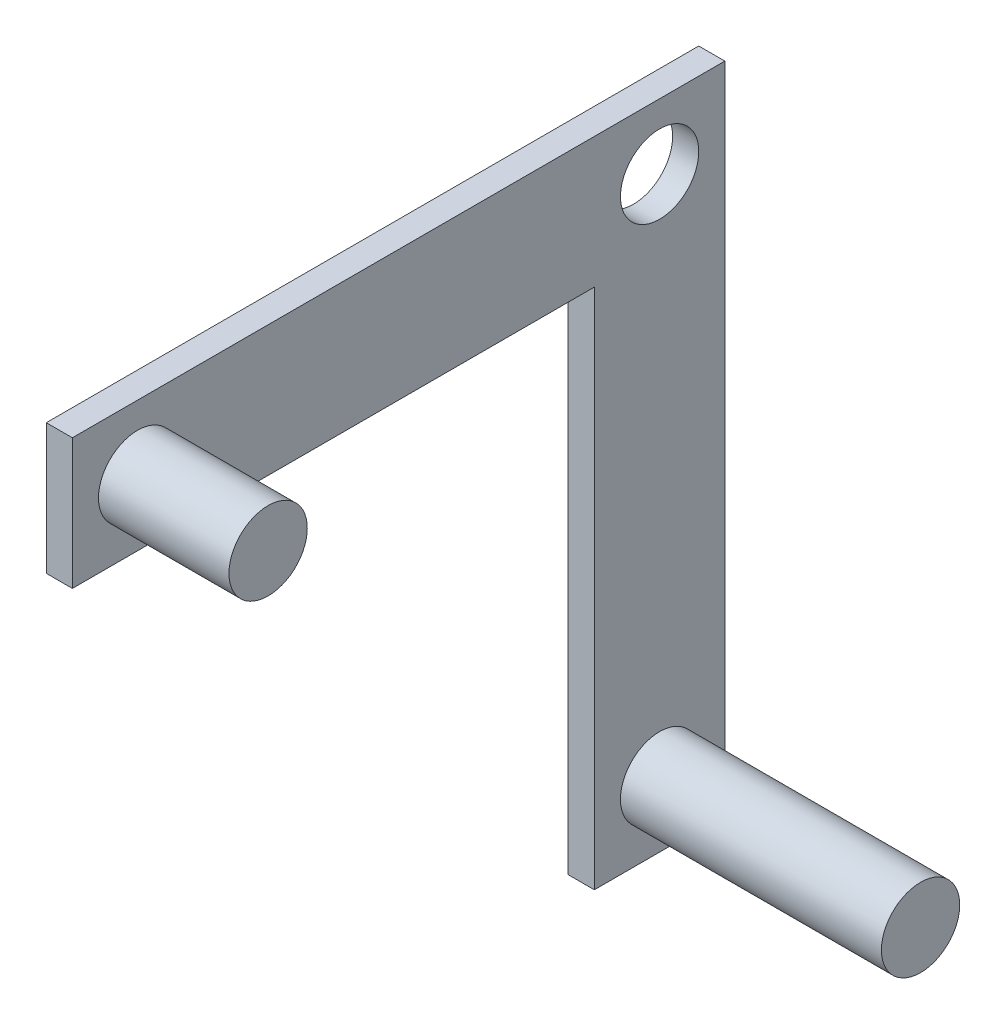
from build123d import *

# Parameters (mm, degrees)
SKETCH1_W           = 10
SKETCH1_H           = 50
BOSS_EXTRUDE1_DEPTH = 2
SKETCH2_R           = 3
CUT_EXTRUDE1_DEPTH  = 2
SKETCH3_R           = 3
BOSS_EXTRUDE2_DEPTH = 20
SKETCH4_W           = 2
SKETCH4_H           = 10
BOSS_EXTRUDE3_DEPTH = 40
SKETCH5_R           = 3
BOSS_EXTRUDE4_DEPTH = 10


with BuildPart() as part:
    # Sketch1 → Boss-Extrude1 (new body)
    with BuildSketch(Plane(origin=(0, 0, 0), x_dir=(0, 0, -1), z_dir=(1, 0, 0))):
        Rectangle(SKETCH1_W, SKETCH1_H)
    extrude(amount=BOSS_EXTRUDE1_DEPTH)

    # Sketch2 → Cut-Extrude1 (cut)
    with BuildSketch(Plane(origin=(2, 0, 0), x_dir=(0, 0, -1), z_dir=(1, 0, 0))):
        with Locations((0, 20)):
            Circle(SKETCH2_R)
    extrude(amount=-CUT_EXTRUDE1_DEPTH, mode=Mode.SUBTRACT)

    # Sketch3 → Boss-Extrude2 (add)
    with BuildSketch(Plane(origin=(2, 0, 0), x_dir=(0, 0, -1), z_dir=(1, 0, 0))):
        with Locations((0, -20)):
            Circle(SKETCH3_R)
    extrude(amount=BOSS_EXTRUDE2_DEPTH)

    # Sketch4 → Boss-Extrude3 (add)
    with BuildSketch(Plane.XY.offset(5)):
        with Locations((1, 20)):
            Rectangle(SKETCH4_W, SKETCH4_H)
    extrude(amount=BOSS_EXTRUDE3_DEPTH)

    # Sketch5 → Boss-Extrude4 (add)
    with BuildSketch(Plane(origin=(2, 0, 0), x_dir=(0, 0, -1), z_dir=(1, 0, 0))):
        with Locations((-40, 20)):
            Circle(SKETCH5_R)
    extrude(amount=BOSS_EXTRUDE4_DEPTH)


solid = part.part
